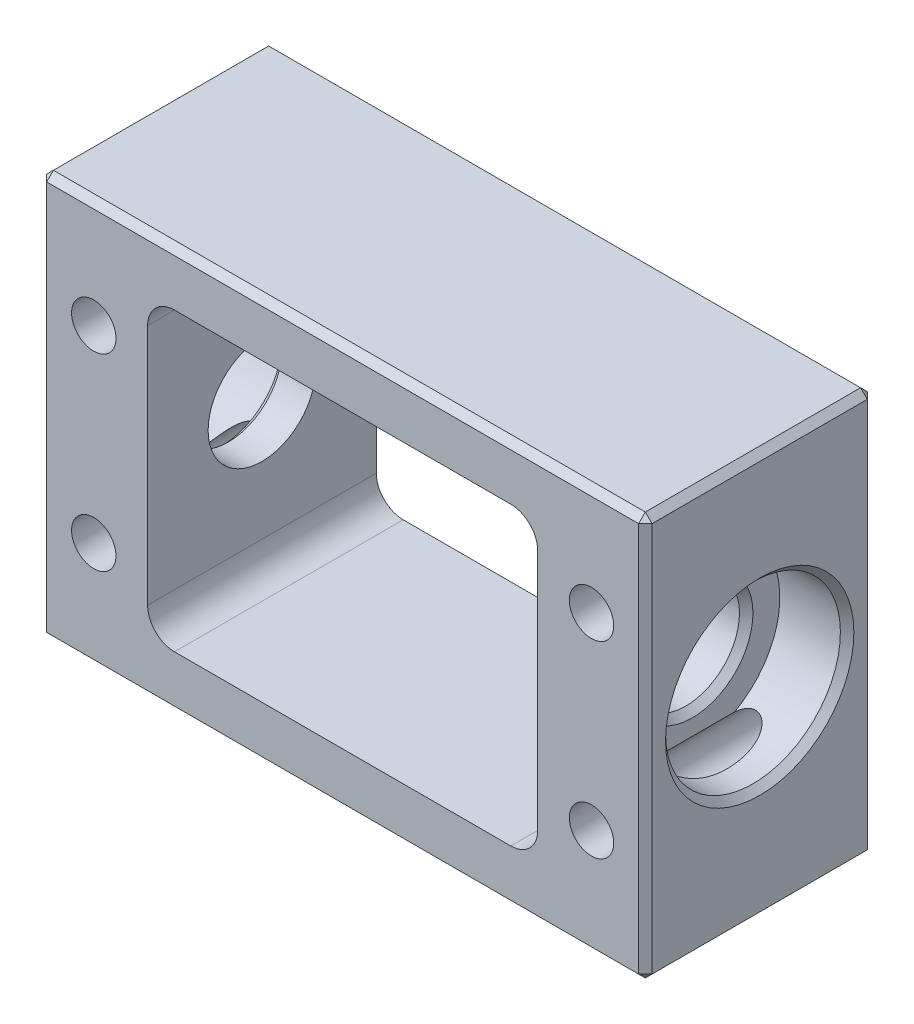
from build123d import *

# Parameters (mm, degrees)
SKETCH_1_W          = 45
SKETCH_1_H          = 30
EXTRUDE_1_DEPTH     = 8.5
SKETCH_2_R          = 6.5
CUT_EXTRUDE_1_DEPTH = 5
SKETCH_3_R          = 4
CUT_EXTRUDE_2_DEPTH = 53
CHAMFER_1_SIZE      = 0.5
HOLE_WIZARD_M4_1_D  = 3.3
SKETCH_7_W          = 29
SKETCH_7_H          = 22
CUT_EXTRUDE_3_DEPTH = 53
FILLET_1_R          = 2
CHAMFER_2_SIZE      = 0.5


with BuildPart() as part:
    # 草图1 → 凸台-拉伸1 (new body, symmetric)
    with BuildSketch(Plane.XY):
        Rectangle(SKETCH_1_W, SKETCH_1_H)
    extrude(amount=EXTRUDE_1_DEPTH, both=True)

    # 草图2 → 切除-拉伸1 (cut)
    with BuildSketch(Plane(origin=(22.5, 0, 0), x_dir=(0, 0, -1), z_dir=(1, 0, 0))):
        Circle(SKETCH_2_R)
    cut_extrude_1 = extrude(amount=-CUT_EXTRUDE_1_DEPTH, mode=Mode.SUBTRACT)

    # 镜向1: 切除-拉伸1 across plane
    add(cut_extrude_1.mirror(Plane(origin=(0, 0, 0), x_dir=(0, 0, 1), z_dir=(1, 0, 0))), mode=Mode.SUBTRACT)

    # 草图3 → 切除-拉伸2 (cut)
    with BuildSketch(Plane(origin=(17.5, 0, 0), x_dir=(0, 0, -1), z_dir=(1, 0, 0))):
        Circle(SKETCH_3_R)
    extrude(amount=-CUT_EXTRUDE_2_DEPTH, mode=Mode.SUBTRACT)

    # 倒角1
    chamfer_1_edges = [part.edges().sort_by_distance(p)[0] for p in [
        (22.5, 0, 6.5),
        (-22.5, 0, 6.5),
        (-17.5, 0, 4),
        (17.5, 0, 4),
    ]]
    chamfer(chamfer_1_edges, length=CHAMFER_1_SIZE)

    # M4 螺纹孔1 (through all)
    with Locations(Plane(origin=(0, 0, -8.5), x_dir=(-1, 0, 0), z_dir=(0, 0, -1))):
        with Locations((-18.5, 7), (18.5, 7), (-18.5, -7), (18.5, -7)):
            Hole(HOLE_WIZARD_M4_1_D / 2)

    # 草图7 → 切除-拉伸3 (cut)
    with BuildSketch(Plane(origin=(0, 0, -8.5), x_dir=(-1, 0, 0), z_dir=(0, 0, -1))):
        Rectangle(SKETCH_7_W, SKETCH_7_H)
    extrude(amount=-CUT_EXTRUDE_3_DEPTH, mode=Mode.SUBTRACT)

    # 圆角1
    fillet_1_edges = [part.edges().sort_by_distance(p)[0] for p in [
        (-14.5, -11, 0),
        (14.5, 11, 0),
        (-14.5, 11, 0),
        (14.5, -11, 0),
    ]]
    fillet(fillet_1_edges, radius=FILLET_1_R)

    # 倒角2
    chamfer_2_edges = [part.edges().sort_by_distance(p)[0] for p in [
        (-22.5, 0, 8.5),
        (0, -15, 8.5),
        (22.5, 0, 8.5),
        (0, -15, -8.5),
        (-22.5, 0, -8.5),
        (0, 15, -8.5),
        (22.5, 0, -8.5),
        (22.5, -15, 0),
        (-22.5, -15, 0),
        (-22.5, 15, 0),
        (22.5, 15, 0),
        (0, 15, 8.5),
    ]]
    chamfer(chamfer_2_edges, length=CHAMFER_2_SIZE)


solid = part.part
